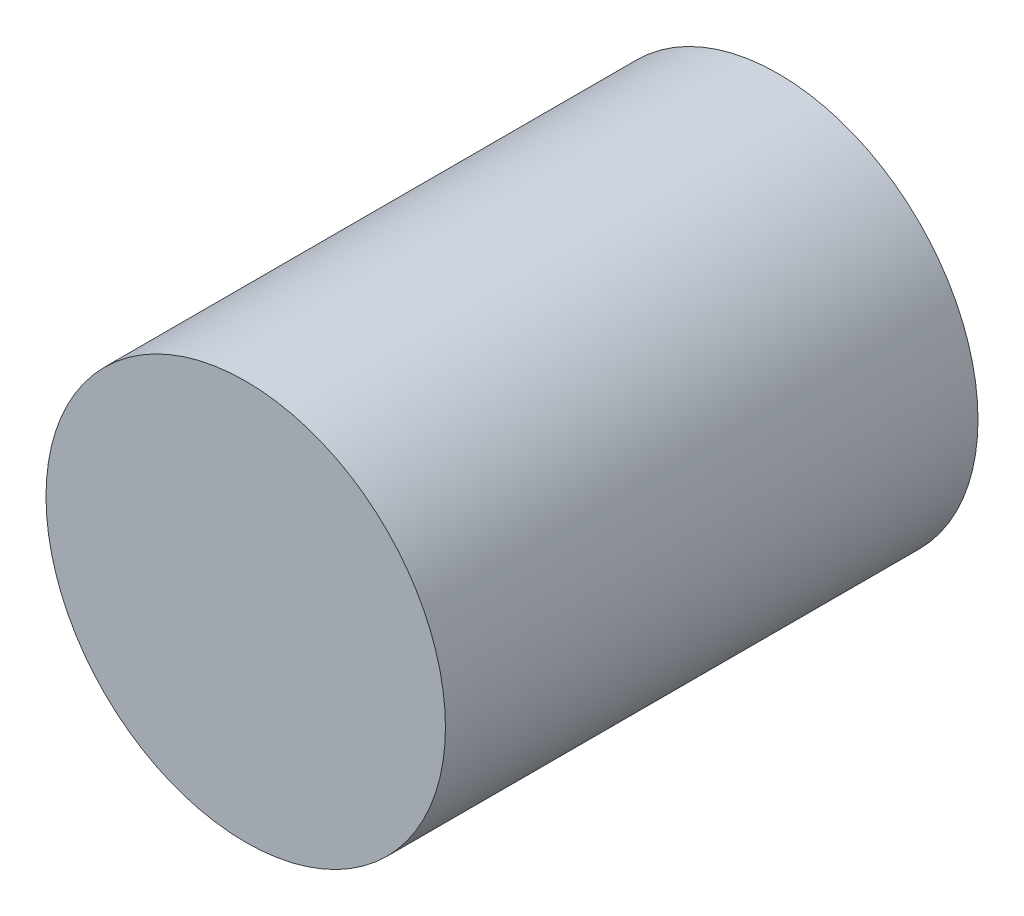
from build123d import *

# Parameters (mm, degrees)
SKETCH2_R           = 4.7625
BOSS_EXTRUDE1_DEPTH = 12.7


with BuildPart() as part:
    # Sketch2 → Boss-Extrude1 (new body)
    with BuildSketch(Plane.XY):
        Circle(SKETCH2_R)
    extrude(amount=BOSS_EXTRUDE1_DEPTH)


solid = part.part
